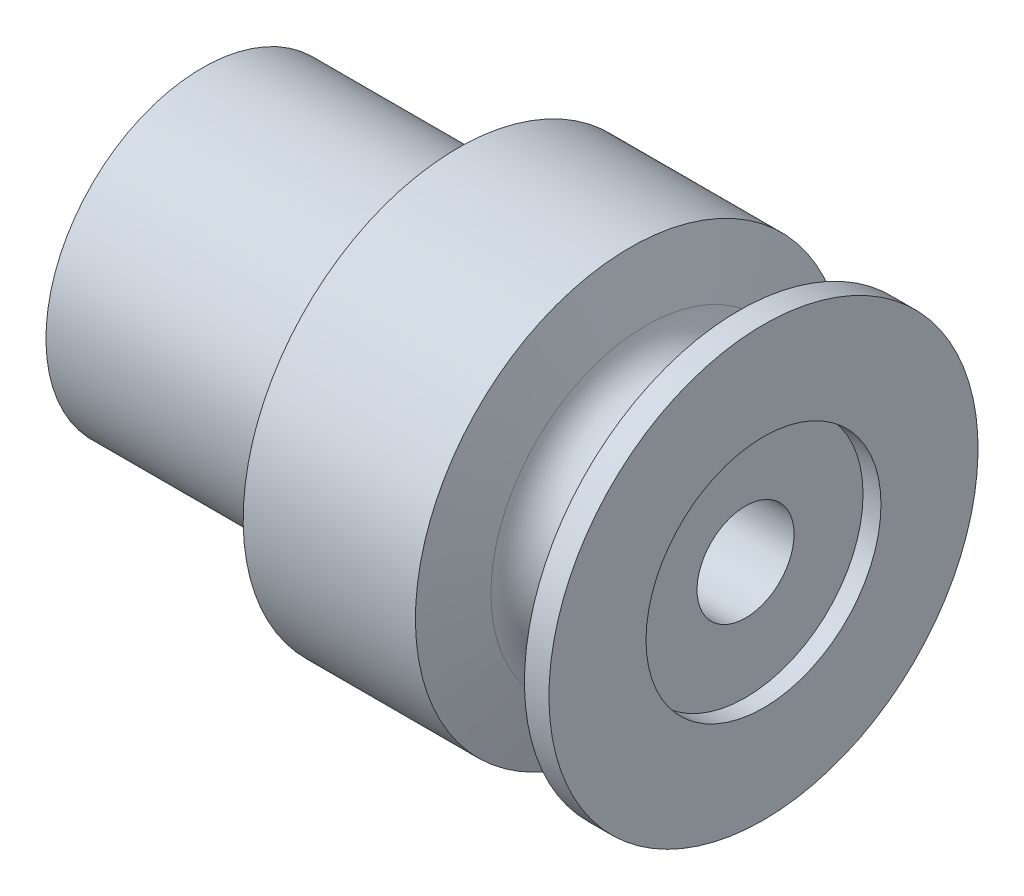
from build123d import *


with BuildPart() as part:
    # Sketch1 → Revolve1 (revolve)
    with BuildSketch(Plane.XY):
        with BuildLine():
            Line((-2.519270709, 7.706480957), (-1.725734073, 10.668))
            Line((-1.725734073, 10.668), (-0.508, 10.668))
            Line((-0.508, 10.668), (-0.508, 5.842))
            Line((-0.508, 5.842), (-1.4, 5.842))
            Line((-1.4, 5.842), (-1.4, 2.413))
            Line((-1.4, 2.413), (-24.068719082, 2.413))
            Line((-24.068719082, 2.413), (-28.412119082, 6.7564))
            Line((-28.412119082, 6.7564), (-28.412119082, 7.7724))
            Line((-28.412119082, 7.7724), (-15.712119082, 7.7724))
            Line((-15.712119082, 7.7724), (-15.712119082, 10.668))
            Line((-15.712119082, 10.668), (-7.146325468, 10.668))
            Line((-7.146325468, 10.668), (-6.352788832, 7.706480957))
            ThreePointArc((-6.352788832, 7.706480957), (-4.43602977, 6.2357), (-2.519270709, 7.706480957))
        make_face()
    revolve(axis=Axis((-22.598839253, 0, 0), (1, 0, 0)))


solid = part.part
